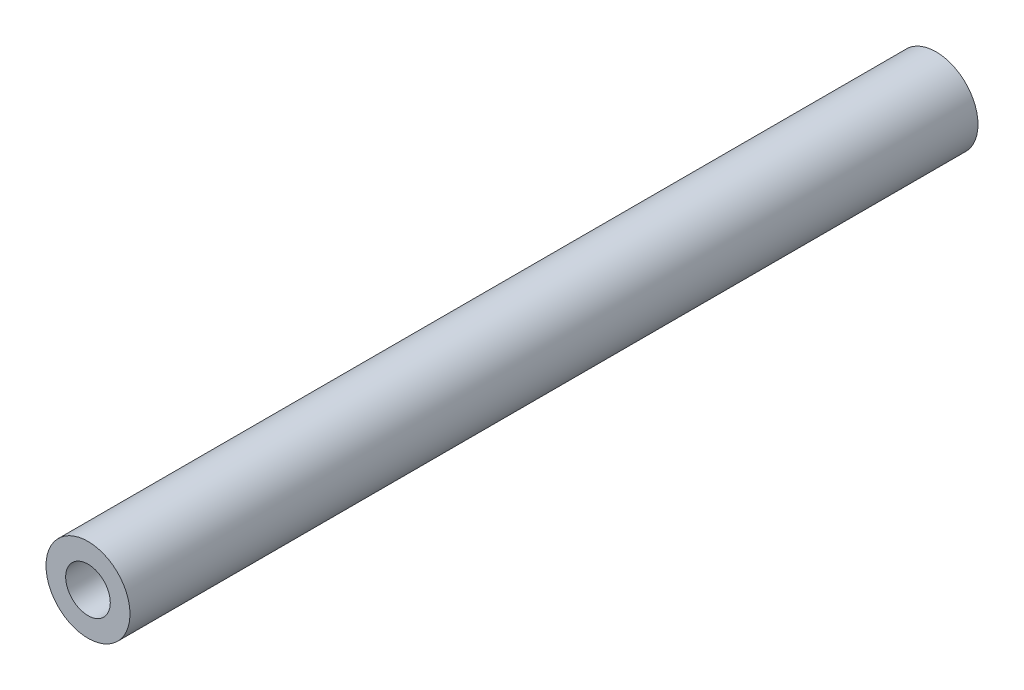
from build123d import *

# Parameters (mm, degrees)
SKETCH_1_R             = 8
EXTRUDE_1_DEPTH        = 161.6
HOLE_WIZARD_M103_D     = 8.5
HOLE_WIZARD_M103_DEPTH = 35
HOLE_WIZARD_M103_TIP   = 2.553657631
HOLE_WIZARD_M104_D     = 8.5
HOLE_WIZARD_M104_DEPTH = 35
HOLE_WIZARD_M104_TIP   = 2.553657631


with BuildPart() as part:
    # Эскиз1 → Бобышка-Вытянуть1 (new body)
    with BuildSketch(Plane.XY):
        with Locations((100, -317)):
            Circle(SKETCH_1_R)
    extrude(amount=EXTRUDE_1_DEPTH)

    # Отверстие обработанное метчиком M103
    with Locations(Plane.XY.offset(161.6)):
        with Locations((100, -317)):
            Hole(HOLE_WIZARD_M103_D / 2, depth=HOLE_WIZARD_M103_DEPTH)
            with Locations((0, 0, -(HOLE_WIZARD_M103_DEPTH + HOLE_WIZARD_M103_TIP / 2))):  # 118° drill point
                Cone(0, HOLE_WIZARD_M103_D / 2, HOLE_WIZARD_M103_TIP, mode=Mode.SUBTRACT)

    # Отверстие обработанное метчиком M104
    with Locations(Plane(origin=(0, 0, 0), x_dir=(-1, 0, 0), z_dir=(0, 0, -1))):
        with Locations((-100, -317)):
            Hole(HOLE_WIZARD_M104_D / 2, depth=HOLE_WIZARD_M104_DEPTH)
            with Locations((0, 0, -(HOLE_WIZARD_M104_DEPTH + HOLE_WIZARD_M104_TIP / 2))):  # 118° drill point
                Cone(0, HOLE_WIZARD_M104_D / 2, HOLE_WIZARD_M104_TIP, mode=Mode.SUBTRACT)


solid = part.part
